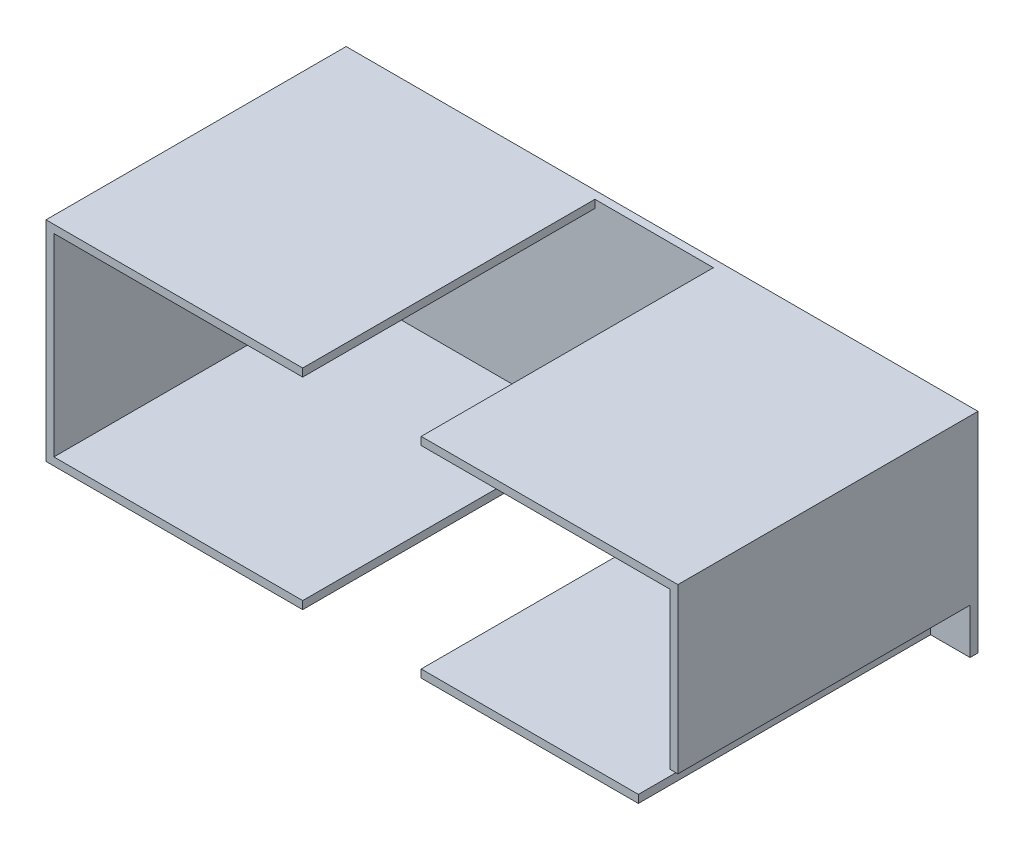
from build123d import *

# Parameters (mm, degrees)
SKETCH1_W           = 160
SKETCH1_H           = 53
BOSS_EXTRUDE1_DEPTH = 76
SKETCH2_W           = 156
SKETCH2_H           = 49
CUT_EXTRUDE1_DEPTH  = 74
CUT_EXTRUDE2_REACH  = 4
SKETCH3_R           = 2
SKETCH4_W           = 30
SKETCH4_H           = 2
SKETCH4_W_2         = 20
SKETCH4_H_2         = 20
CUT_EXTRUDE3_DEPTH  = 74


with BuildPart() as part:
    # Sketch1 → Boss-Extrude1 (new body)
    with BuildSketch(Plane.XY):
        Rectangle(SKETCH1_W, SKETCH1_H)
    extrude(amount=BOSS_EXTRUDE1_DEPTH)

    # Sketch2 → Cut-Extrude1 (cut)
    with BuildSketch(Plane.XY.offset(76)):
        Rectangle(SKETCH2_W, SKETCH2_H)
    extrude(amount=-CUT_EXTRUDE1_DEPTH, mode=Mode.SUBTRACT)

    # Sketch3 → Cut-Extrude2 (cut, up to next)
    with BuildSketch(Plane.XY.offset(2), mode=Mode.PRIVATE) as cut_extrude2_sk1:
        with Locations((50, 0)):
            Circle(SKETCH3_R)
    cut_extrude2_tool1 = extrude(cut_extrude2_sk1.sketch, amount=-CUT_EXTRUDE2_REACH, mode=Mode.PRIVATE) & part.part
    add(cut_extrude2_tool1.solids().sort_by_distance((50, 0, 2))[0], mode=Mode.SUBTRACT)
    # Sketch3 → Cut-Extrude2 (cut, up to next)
    with BuildSketch(Plane.XY.offset(2), mode=Mode.PRIVATE) as cut_extrude2_sk2:
        with Locations((-50, 0)):
            Circle(SKETCH3_R)
    cut_extrude2_tool2 = extrude(cut_extrude2_sk2.sketch, amount=-CUT_EXTRUDE2_REACH, mode=Mode.PRIVATE) & part.part
    add(cut_extrude2_tool2.solids().sort_by_distance((-50, 0, 2))[0], mode=Mode.SUBTRACT)

    # Sketch4 → Cut-Extrude3 (cut)
    with BuildSketch(Plane.XY.offset(76)):
        with Locations((0, 25.5)):
            Rectangle(SKETCH4_W, SKETCH4_H)
        with Locations((0, -25.5)):
            Rectangle(SKETCH4_W, SKETCH4_H)
        with Locations((80, -25)):
            Rectangle(SKETCH4_W_2, SKETCH4_H_2)
    extrude(amount=-CUT_EXTRUDE3_DEPTH, mode=Mode.SUBTRACT)


solid = part.part
